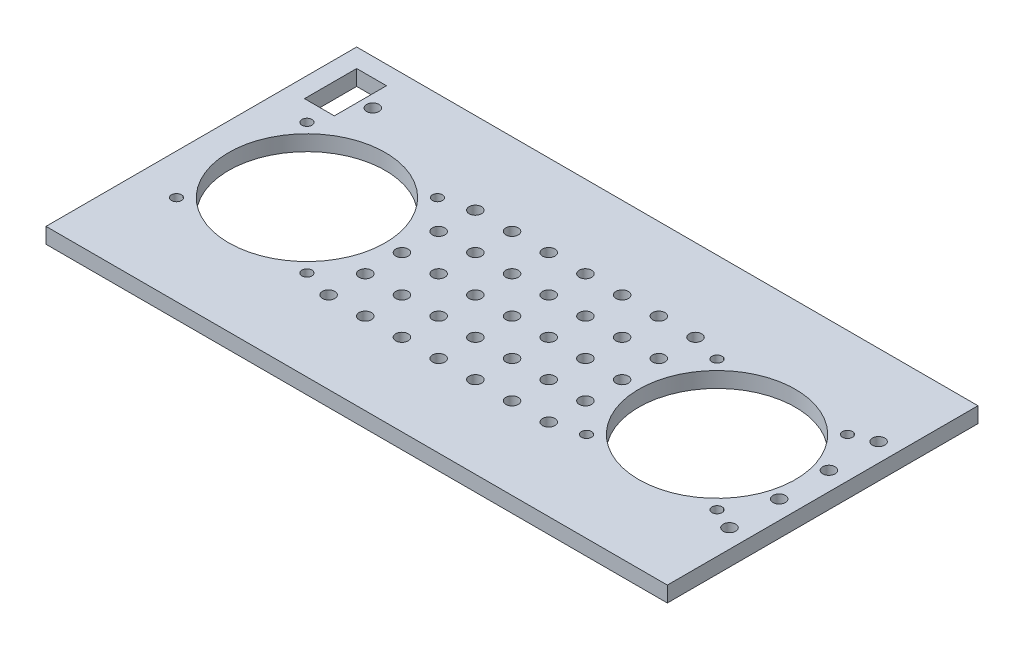
from build123d import *

# Parameters (mm, degrees)
SKETCH1_W            = 254
SKETCH1_H            = 127
BOSS_EXTRUDE1_DEPTH  = 6.35
SKETCH3_R            = 2.54
CUT_EXTRUDE3_DEPTH   = 25.4
LPATTERN1_COUNT      = 4
LPATTERN1_PITCH      = 20.32
SKETCH3_7_R          = 2.54
CUT_EXTRUDE4_DEPTH   = 25.4
LPATTERN2_COUNT      = 7
LPATTERN2_PITCH      = 14.9999954
LPATTERN2_COUNT_DIR2 = 5
LPATTERN2_PITCH_DIR2 = 14.9999954
SKETCH3_8_R          = 32.004
SKETCH3_8_R_2        = 2.54
SKETCH3_8_R_3        = 2.0574
SKETCH3_8_W          = 12.192
SKETCH3_8_H          = 21.336
CUT_EXTRUDE5_DEPTH   = 25.4


with BuildPart() as part:
    # Sketch1 → Boss-Extrude1 (new body)
    with BuildSketch(Plane(origin=(0, 0, 0), x_dir=(1, 0, 0), z_dir=(0, 1, 0))):
        with Locations((-62.014339623, -15.479622642)):
            Rectangle(SKETCH1_W, SKETCH1_H)
    extrude(amount=BOSS_EXTRUDE1_DEPTH)

    # Sketch3 → Cut-Extrude3 (cut)
    with BuildSketch(Plane(origin=(0, 6.35, 0), x_dir=(1, 0, 0), z_dir=(0, 1, 0))):
        with Locations((57.365660377, 15.000377358)):
            Circle(SKETCH3_R)
    cut_extrude3 = extrude(amount=-CUT_EXTRUDE3_DEPTH, mode=Mode.SUBTRACT)

    # LPattern1: Cut-Extrude3 ×4
    with Locations(*[(0, 0, i * LPATTERN1_PITCH) for i in range(1, LPATTERN1_COUNT)]):
        add(cut_extrude3, mode=Mode.SUBTRACT)

    # Sketch3_7 → Cut-Extrude4 (cut)
    with BuildSketch(Plane(origin=(0, 6.35, 0), x_dir=(1, 0, 0), z_dir=(0, 1, 0))):
        with Locations((-106.972339623, 14.492377358)):
            Circle(SKETCH3_7_R)
    cut_extrude4 = extrude(amount=-CUT_EXTRUDE4_DEPTH, mode=Mode.SUBTRACT)

    # LPattern2: Cut-Extrude4 7 × 5
    with Locations(*[(i * LPATTERN2_PITCH, 0, j * LPATTERN2_PITCH_DIR2) for i in range(LPATTERN2_COUNT) for j in range(LPATTERN2_COUNT_DIR2) if (i, j) != (0, 0)]):
        add(cut_extrude4, mode=Mode.SUBTRACT)

    # Sketch3_8 → Cut-Extrude5 (cut)
    with BuildSketch(Plane(origin=(0, 6.35, 0), x_dir=(1, 0, 0), z_dir=(0, 1, 0))):
        with Locations((-145.834339623, -15.479622642)):
            Circle(SKETCH3_8_R)
        with Locations((21.805660377, -15.479622642)):
            Circle(SKETCH3_8_R)
        with Locations((-106.972339623, 14.492377358)):
            Circle(SKETCH3_8_R_2)
        with Locations((-172.504339623, -42.149622642)):
            Circle(SKETCH3_8_R_3)
        with Locations((57.365660377, 15.000377358)):
            Circle(SKETCH3_8_R_2)
        with Locations((-164.122339623, 29.732377358)):
            Circle(SKETCH3_8_R_2)
        with Locations((-119.164339623, -42.149622642)):
            Circle(SKETCH3_8_R_3)
        with Locations((-172.504339623, 11.190377358)):
            Circle(SKETCH3_8_R_3)
        with Locations((-119.164339623, 11.190377358)):
            Circle(SKETCH3_8_R_3)
        with Locations((-4.864339623, -42.149622642)):
            Circle(SKETCH3_8_R_3)
        with Locations((48.475660377, -42.149622642)):
            Circle(SKETCH3_8_R_3)
        with Locations((-4.864339623, 11.190377358)):
            Circle(SKETCH3_8_R_3)
        with Locations((48.475660377, 11.190377358)):
            Circle(SKETCH3_8_R_3)
        with Locations((-175.298339623, 29.732377358)):
            Rectangle(SKETCH3_8_W, SKETCH3_8_H)
    extrude(amount=-CUT_EXTRUDE5_DEPTH, mode=Mode.SUBTRACT)


solid = part.part
